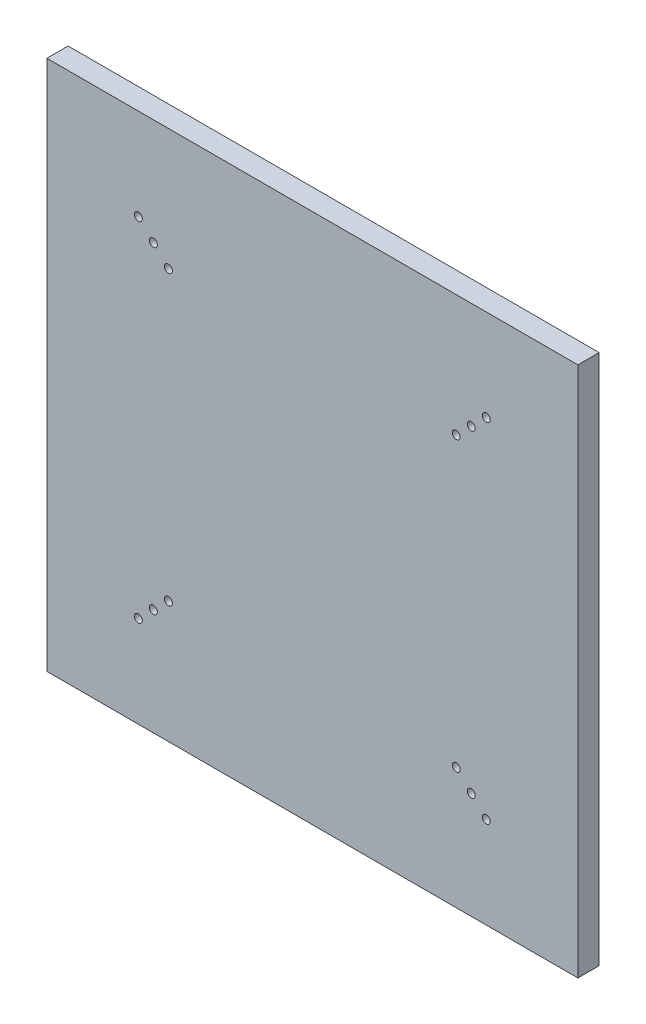
from build123d import *

# Parameters (mm, degrees)
SKETCH1_W           = 200
SKETCH1_H           = 200
BOSS_EXTRUDE1_DEPTH = 8
SKETCH3_R           = 1.5
CUT_EXTRUDE1_DEPTH  = 4
SKETCH4_R           = 2.5
CUT_EXTRUDE2_DEPTH  = 10
CIRPATTERN1_COUNT   = 4


with BuildPart() as part:
    # Sketch1 → Boss-Extrude1 (new body)
    with BuildSketch(Plane.XY):
        with Locations((100, 100)):
            Rectangle(SKETCH1_W, SKETCH1_H)
    extrude(amount=BOSS_EXTRUDE1_DEPTH)

    # Sketch3 → Cut-Extrude1 (cut)
    with BuildSketch(Plane.XY.offset(8)):
        with Locations((165.495689012, 34.504310988)):
            Circle(SKETCH3_R)
        with Locations((159.838834762, 40.161165238)):
            Circle(SKETCH3_R)
        with Locations((154.181980513, 45.818019487)):
            Circle(SKETCH3_R)
    cut_extrude1 = extrude(amount=-CUT_EXTRUDE1_DEPTH, mode=Mode.SUBTRACT)

    # Sketch4 → Cut-Extrude2 (cut)
    with BuildSketch(Plane.XY.offset(4)):
        with Locations((154.181980513, 45.818019487)):
            Circle(SKETCH4_R)
        with Locations((159.838834762, 40.161165238)):
            Circle(SKETCH4_R)
        with Locations((165.495689012, 34.504310988)):
            Circle(SKETCH4_R)
    cut_extrude2 = extrude(amount=-CUT_EXTRUDE2_DEPTH, mode=Mode.SUBTRACT)

    # CirPattern1: Cut-Extrude1, Cut-Extrude2 ×4 about axis
    cirpattern1_axis = Axis((99.968259988, 100.031740012, 8), (0, 0, 1))
    add([cut_extrude1.rotate(cirpattern1_axis, i * 360 / CIRPATTERN1_COUNT) for i in range(1, CIRPATTERN1_COUNT)], mode=Mode.SUBTRACT)
    add([cut_extrude2.rotate(cirpattern1_axis, i * 360 / CIRPATTERN1_COUNT) for i in range(1, CIRPATTERN1_COUNT)], mode=Mode.SUBTRACT)


solid = part.part
